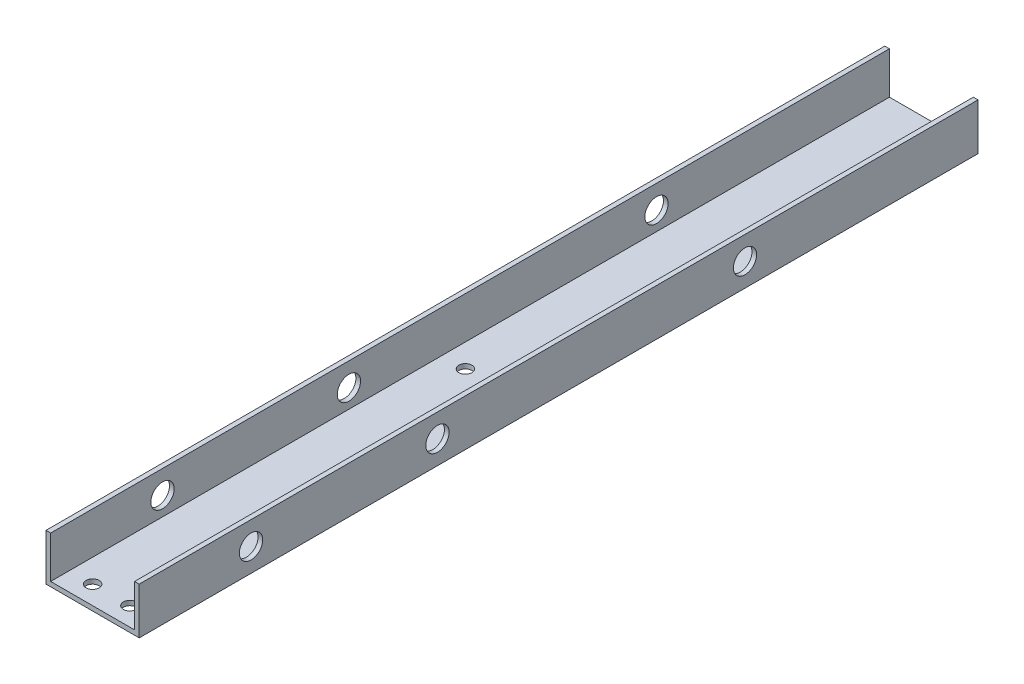
from build123d import *

# Parameters (mm, degrees)
BOSS_EXTRUDE1_DEPTH = 457.2
CUT_EXTRUDE1_REACH  = 27.4
SKETCH2_R           = 3.556
CUT_EXTRUDE2_REACH  = 27.4
SKETCH3_R           = 3.556
SKETCH4_R           = 6.35
CUT_EXTRUDE3_DEPTH  = 51.8


with BuildPart() as part:
    # Sketch1 → Boss-Extrude1 (new body)
    with BuildSketch(Plane.XY):
        Polygon((48.26, 2.54), (48.26, 25.4), (50.8, 25.4), (50.8, 0), (0, 0), (0, 25.4), (2.54, 25.4), (2.54, 2.54), align=None)
    extrude(amount=BOSS_EXTRUDE1_DEPTH)

    # Sketch2 → Cut-Extrude1 (cut, up to next)
    with BuildSketch(Plane.XZ, mode=Mode.PRIVATE) as cut_extrude1_sk1:
        with Locations((15.24, 447.04)):
            Circle(SKETCH2_R)
    cut_extrude1_tool1 = extrude(cut_extrude1_sk1.sketch, amount=-CUT_EXTRUDE1_REACH, mode=Mode.PRIVATE) & part.part
    add(cut_extrude1_tool1.solids().sort_by_distance((15.24, 0, 447.04))[0], mode=Mode.SUBTRACT)
    # Sketch2 → Cut-Extrude1 (cut, up to next)
    with BuildSketch(Plane.XZ, mode=Mode.PRIVATE) as cut_extrude1_sk2:
        with Locations((35.56, 447.04)):
            Circle(SKETCH2_R)
    cut_extrude1_tool2 = extrude(cut_extrude1_sk2.sketch, amount=-CUT_EXTRUDE1_REACH, mode=Mode.PRIVATE) & part.part
    add(cut_extrude1_tool2.solids().sort_by_distance((35.56, 0, 447.04))[0], mode=Mode.SUBTRACT)

    # Sketch3 → Cut-Extrude2 (cut, up to next)
    with BuildSketch(Plane.XZ, mode=Mode.PRIVATE) as cut_extrude2_sk1:
        with Locations((15.24, 243.84)):
            Circle(SKETCH3_R)
    cut_extrude2_tool1 = extrude(cut_extrude2_sk1.sketch, amount=-CUT_EXTRUDE2_REACH, mode=Mode.PRIVATE) & part.part
    add(cut_extrude2_tool1.solids().sort_by_distance((15.24, 0, 243.84))[0], mode=Mode.SUBTRACT)
    # Sketch3 → Cut-Extrude2 (cut, up to next)
    with BuildSketch(Plane.XZ, mode=Mode.PRIVATE) as cut_extrude2_sk2:
        with Locations((35.56, 243.84)):
            Circle(SKETCH3_R)
    cut_extrude2_tool2 = extrude(cut_extrude2_sk2.sketch, amount=-CUT_EXTRUDE2_REACH, mode=Mode.PRIVATE) & part.part
    add(cut_extrude2_tool2.solids().sort_by_distance((35.56, 0, 243.84))[0], mode=Mode.SUBTRACT)

    # Sketch4 → Cut-Extrude3 (cut, through all)
    with BuildSketch(Plane.ZY):
        with Locations((396.24, 12.7)):
            Circle(SKETCH4_R)
        with Locations((294.64, 12.7)):
            Circle(SKETCH4_R)
        with Locations((127, 12.7)):
            Circle(SKETCH4_R)
    extrude(amount=-CUT_EXTRUDE3_DEPTH, mode=Mode.SUBTRACT)


solid = part.part
